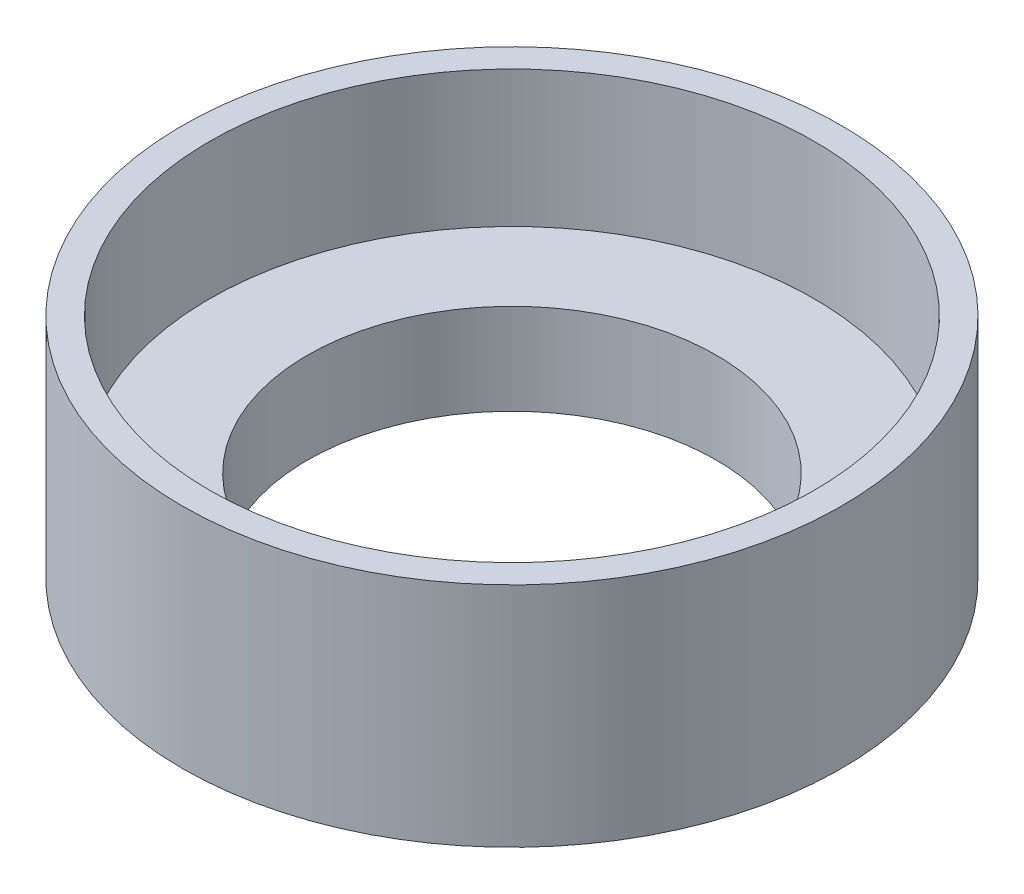
from build123d import *

# Parameters (mm, degrees)
SKETCH1_R               = 18.415
BOSS_EXTRUDE1_DEPTH     = 12.7
SKETCH2_R               = 16.891
CUT_EXTRUDE1_DEPTH      = 7.62
SKETCH3_R               = 11.43
CUT_EXTRUDE2_DEPTH      = 8.62
CUT_EXTRUDE2_DEPTH_BACK = 6.08


with BuildPart() as part:
    # Sketch1 → Boss-Extrude1 (new body)
    with BuildSketch(Plane(origin=(0, 0, 0), x_dir=(1, 0, 0), z_dir=(0, 1, 0))):
        Circle(SKETCH1_R)
    extrude(amount=BOSS_EXTRUDE1_DEPTH)

    # Sketch2 → Cut-Extrude1 (cut)
    with BuildSketch(Plane(origin=(0, 12.7, 0), x_dir=(1, 0, 0), z_dir=(0, 1, 0))):
        Circle(SKETCH2_R)
    extrude(amount=-CUT_EXTRUDE1_DEPTH, mode=Mode.SUBTRACT)

    # Sketch3 → Cut-Extrude2 (cut, two sides)
    with BuildSketch(Plane(origin=(0, 5.08, 0), x_dir=(1, 0, 0), z_dir=(0, 1, 0))) as cut_extrude2_sk:
        Circle(SKETCH3_R)
    extrude(amount=CUT_EXTRUDE2_DEPTH, mode=Mode.SUBTRACT)
    extrude(cut_extrude2_sk.sketch, amount=-CUT_EXTRUDE2_DEPTH_BACK, mode=Mode.SUBTRACT)


solid = part.part
